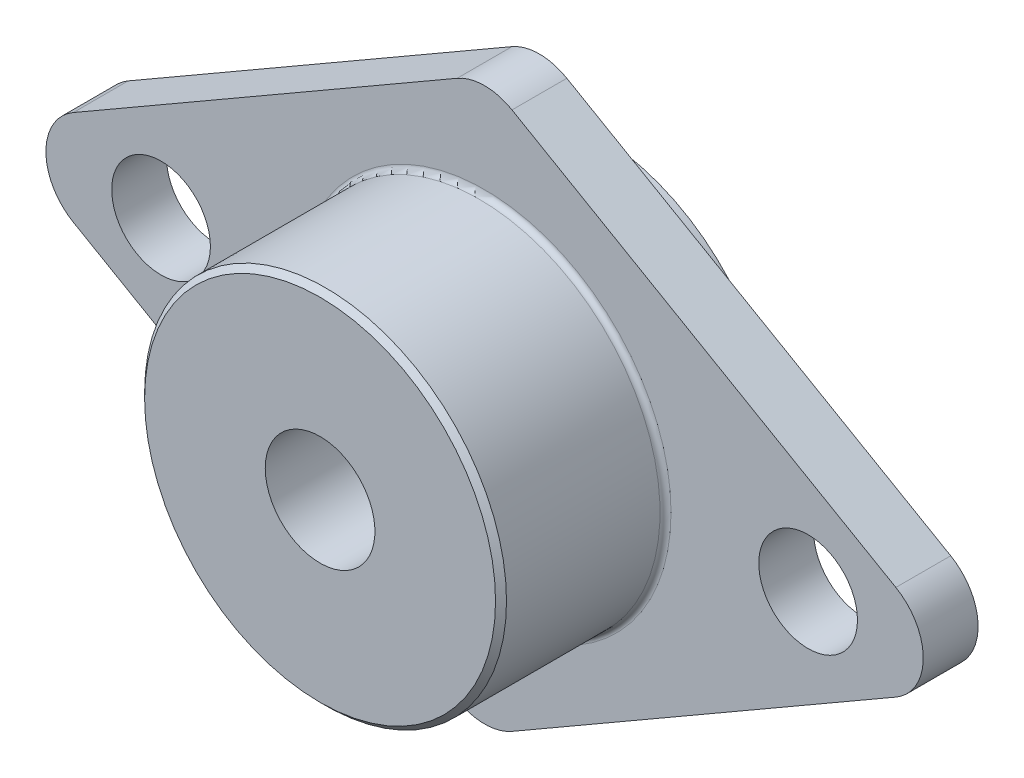
from build123d import *

# Parameters (mm, degrees)
BOSS_EXTRU_1_DEPTH      = 5
ESQUISSE3_R             = 16.5
BOSS_EXTRU_2_DEPTH      = 15
ESQUISSE4_R             = 16.5
BOSS_EXTRU_3_DEPTH      = 5
ESQUISSE5_R             = 5
ENL_V_MAT_EXTRU_1_DEPTH = 26
ESQUISSE6_R             = 4.5
ENL_V_MAT_EXTRU_2_DEPTH = 5
CONG_1_R                = 0.5
CHANFREIN1_SIZE         = 0.5


with BuildPart() as part:
    # Esquisse2 → Boss.-Extru.1 (new body)
    with BuildSketch(Plane.XY):
        with BuildLine():
            Line((-37.5, 4.330127019), (-2.5, 24.537386441))
            ThreePointArc((-2.5, 24.537386441), (0, 25.207259422), (2.5, 24.537386441))
            Line((2.5, 24.537386441), (37.5, 4.330127019))
            ThreePointArc((37.5, 4.330127019), (40, 0), (37.5, -4.330127019))
            Line((37.5, -4.330127019), (2.5, -24.537386441))
            ThreePointArc((2.5, -24.537386441), (0, -25.207259422), (-2.5, -24.537386441))
            Line((-2.5, -24.537386441), (-37.5, -4.330127019))
            ThreePointArc((-37.5, -4.330127019), (-40, 0), (-37.5, 4.330127019))
        make_face()
    extrude(amount=BOSS_EXTRU_1_DEPTH)

    # Esquisse3 → Boss.-Extru.2 (add)
    with BuildSketch(Plane.XY.offset(5)):
        with Locations(Location((0, 0, 0), (0, 0, 180))):  # turned: the seam where the file's is
            Circle(ESQUISSE3_R)
    extrude(amount=BOSS_EXTRU_2_DEPTH)

    # Esquisse4 → Boss.-Extru.3 (add)
    with BuildSketch(Plane(origin=(0, 0, 0), x_dir=(-1, 0, 0), z_dir=(0, 0, -1))):
        Circle(ESQUISSE4_R)
    extrude(amount=BOSS_EXTRU_3_DEPTH)

    # Esquisse5 → Enlèv. mat.-Extru.1 (cut, through all)
    with BuildSketch(Plane(origin=(0, 0, -5), x_dir=(-1, 0, 0), z_dir=(0, 0, -1))):
        Circle(ESQUISSE5_R)
    extrude(amount=-ENL_V_MAT_EXTRU_1_DEPTH, mode=Mode.SUBTRACT)

    # Esquisse6 → Enlèv. mat.-Extru.2 (cut)
    with BuildSketch(Plane.XY.offset(5)):
        with Locations((29.5, 0)):
            Circle(ESQUISSE6_R)
        with Locations((-29.5, 0)):
            Circle(ESQUISSE6_R)
    extrude(amount=-ENL_V_MAT_EXTRU_2_DEPTH, mode=Mode.SUBTRACT)

    # Congé1
    cong_1_edges = [part.edges().sort_by_distance(p)[0] for p in [
        (16.5, 0, 5),
        (16.5, 0, 0),
    ]]
    fillet(cong_1_edges, radius=CONG_1_R)

    # Chanfrein1
    chanfrein1_edges = [part.edges().sort_by_distance(p)[0] for p in [
        (16.5, 0, 20),
    ]]
    chamfer(chanfrein1_edges, length=CHANFREIN1_SIZE)


solid = part.part
